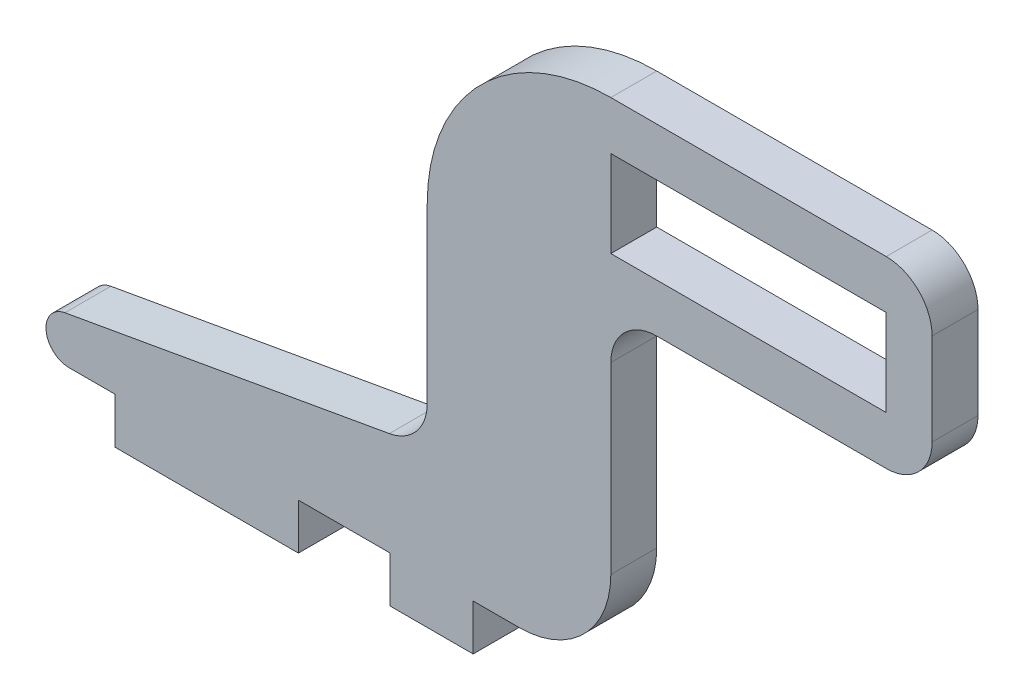
from build123d import *

# Parameters (mm, degrees)
SKETCH1_W           = 19.05
SKETCH1_H           = 5.9944
BOSS_EXTRUDE1_DEPTH = 3.175
FILLET1_R           = 3.175
FILLET2_R           = 3.175


with BuildPart() as part:
    # Sketch1 → Boss-Extrude1 (new body)
    with BuildSketch(Plane.XY):
        with BuildLine():
            Line((0, 3.175), (6.35, 3.175))
            Line((6.35, 3.175), (6.35, 0))
            Line((6.35, 0), (12.087173363, 0))
            Line((12.087173363, 0), (12.087173363, 3.175))
            Line((12.087173363, 3.175), (15.262173363, 3.175))
            ThreePointArc((15.262173363, 3.175), (19.752301423, 5.034871939), (21.612173363, 9.525))
            Line((21.612173363, 9.525), (21.612173363, 25.4))
            Line((21.612173363, 25.4), (43.837173363, 25.4))
            Line((43.837173363, 25.4), (43.837173363, 38.1))
            Line((43.837173363, 38.1), (21.612173363, 38.1))
            ThreePointArc((21.612173363, 38.1), (12.631917242, 34.380256121), (8.912173363, 25.4))
            Line((8.912173363, 25.4), (8.912173363, 10.772098947))
            Line((8.912173363, 10.772098947), (-16.152297099, 6.325593909))
            ThreePointArc((-16.152297099, 6.325593909), (-17.456386706, 4.623315466), (-15.875, 3.175))
            Line((-15.875, 3.175), (-12.7, 3.175))
            Line((-12.7, 3.175), (-12.7, 0))
            Line((-12.7, 0), (0, 0))
            Line((0, 0), (0, 3.175))
        make_face()
        with Locations((31.137173363, 31.75)):
            Rectangle(SKETCH1_W, SKETCH1_H, mode=Mode.SUBTRACT)
    extrude(amount=BOSS_EXTRUDE1_DEPTH)

    # Fillet1
    fillet1_edges = [part.edges().sort_by_distance(p)[0] for p in [
        (8.912173363, 10.772098947, 1.5875),
        (21.612173363, 25.4, 1.5875),
    ]]
    fillet(fillet1_edges, radius=FILLET1_R)

    # Fillet2
    fillet2_edges = [part.edges().sort_by_distance(p)[0] for p in [
        (43.837173363, 38.1, 1.5875),
        (43.837173363, 25.4, 1.5875),
    ]]
    fillet(fillet2_edges, radius=FILLET2_R)


solid = part.part
